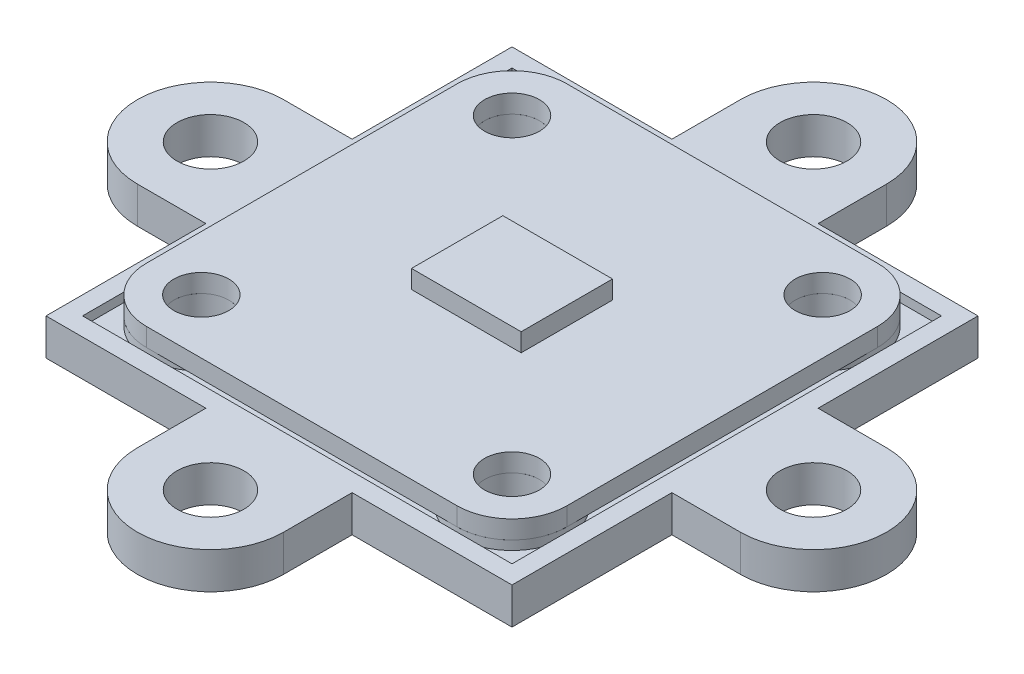
from build123d import *

# Parameters (mm, degrees)
SKETCH1_W           = 23
SKETCH1_H           = 23
SKETCH1_R           = 1.5
BOSS_EXTRUDE1_DEPTH = 1
SKETCH2_W           = 6
SKETCH2_H           = 5
BOSS_EXTRUDE2_DEPTH = 1
FILLET1_R           = 3
BOSS_EXTRUDE3_START = -3
SKETCH3_W           = 25.5
SKETCH3_H           = 25.5
SKETCH3_R           = 1.5
SKETCH3_R_2         = 7.5
BOSS_EXTRUDE3_DEPTH = 1.5
SKETCH4_R           = 3
SKETCH4_R_2         = 1.5
BOSS_EXTRUDE4_DEPTH = 2
SKETCH5_W           = 25.5
SKETCH5_H           = 25.5
SKETCH5_W_2         = 23.5
SKETCH5_H_2         = 23.5
BOSS_EXTRUDE5_DEPTH = 2
SKETCH6_R           = 1.8288
BOSS_EXTRUDE6_DEPTH = 2
CIRPATTERN1_COUNT   = 4


with BuildPart() as part:
    # Sketch1 → Boss-Extrude1 (new body)
    with BuildSketch(Plane(origin=(0, 0, 0), x_dir=(1, 0, 0), z_dir=(0, 1, 0))):
        Rectangle(SKETCH1_W, SKETCH1_H)
        with Locations((-8.5, 8.5)):
            Circle(SKETCH1_R, mode=Mode.SUBTRACT)
        with Locations((8.5, 8.5)):
            Circle(SKETCH1_R, mode=Mode.SUBTRACT)
        with Locations((8.5, -8.5)):
            Circle(SKETCH1_R, mode=Mode.SUBTRACT)
        with Locations((-8.5, -8.5)):
            Circle(SKETCH1_R, mode=Mode.SUBTRACT)
    extrude(amount=BOSS_EXTRUDE1_DEPTH)

    # Sketch2 → Boss-Extrude2 (add)
    with BuildSketch(Plane(origin=(0, 1, 0), x_dir=(1, 0, 0), z_dir=(0, 1, 0))):
        Rectangle(SKETCH2_W, SKETCH2_H)
    extrude(amount=BOSS_EXTRUDE2_DEPTH)

    # Fillet1
    fillet1_edges = [part.edges().sort_by_distance(p)[0] for p in [
        (11.5, 0.5, 11.5),
        (-11.5, 0.5, 11.5),
        (-11.5, 0.5, -11.5),
        (11.5, 0.5, -11.5),
    ]]
    fillet(fillet1_edges, radius=FILLET1_R)


with BuildPart() as body_2:
    # Sketch3 → Boss-Extrude3 (new body)
    with BuildSketch(Plane(origin=(0, 1, 0), x_dir=(1, 0, 0), z_dir=(0, 1, 0)).offset(BOSS_EXTRUDE3_START)):
        Rectangle(SKETCH3_W, SKETCH3_H)
        with Locations((-8.5, 8.5)):
            Circle(SKETCH3_R, mode=Mode.SUBTRACT)
        with Locations((8.5, 8.5)):
            Circle(SKETCH3_R, mode=Mode.SUBTRACT)
        with Locations((8.5, -8.5)):
            Circle(SKETCH3_R, mode=Mode.SUBTRACT)
        with Locations((-8.5, -8.5)):
            Circle(SKETCH3_R, mode=Mode.SUBTRACT)
        Circle(SKETCH3_R_2, mode=Mode.SUBTRACT)
    extrude(amount=BOSS_EXTRUDE3_DEPTH)

    # Sketch4 → Boss-Extrude4 (add)
    with BuildSketch(Plane.XZ.offset(2)):
        with Locations((-8.5, 8.5)):
            Circle(SKETCH4_R)
        with Locations((-8.5, 8.5)):
            Circle(SKETCH4_R_2, mode=Mode.SUBTRACT)
        with Locations((8.5, 8.5)):
            Circle(SKETCH4_R)
        with Locations((8.5, 8.5)):
            Circle(SKETCH4_R_2, mode=Mode.SUBTRACT)
        with Locations((8.5, -8.5)):
            Circle(SKETCH4_R)
        with Locations((8.5, -8.5)):
            Circle(SKETCH4_R_2, mode=Mode.SUBTRACT)
        with Locations((-8.5, -8.5)):
            Circle(SKETCH4_R)
        with Locations((-8.5, -8.5)):
            Circle(SKETCH4_R_2, mode=Mode.SUBTRACT)
    extrude(amount=-BOSS_EXTRUDE4_DEPTH)

    # Sketch5 → Boss-Extrude5 (add)
    with BuildSketch(Plane.XZ.offset(2)):
        Rectangle(SKETCH5_W, SKETCH5_H)
        Rectangle(SKETCH5_W_2, SKETCH5_H_2, mode=Mode.SUBTRACT)
    extrude(amount=-BOSS_EXTRUDE5_DEPTH)

    # Sketch6 → Boss-Extrude6 (add)
    with BuildSketch(Plane(origin=(0, 0, 0), x_dir=(-1, 0, 0), z_dir=(0, 1, 0))):
        with BuildLine():
            Line((-4, -16.5), (-4, -12.75))
            Line((-4, -12.75), (4, -12.75))
            Line((4, -12.75), (4, -16.5))
            ThreePointArc((4, -16.5), (0, -20.5), (-4, -16.5))
        make_face()
        with Locations((0, -16.5)):
            Circle(SKETCH6_R, mode=Mode.SUBTRACT)
    boss_extrude6 = extrude(amount=-BOSS_EXTRUDE6_DEPTH)

    # CirPattern1: Boss-Extrude6 ×4 about axis
    cirpattern1_axis = Axis((0, 0, 0), (0, 1, 0))
    for i in range(1, CIRPATTERN1_COUNT):
        add(boss_extrude6.rotate(cirpattern1_axis, i * 360 / CIRPATTERN1_COUNT))


solid = Compound([part.part, body_2.part])
